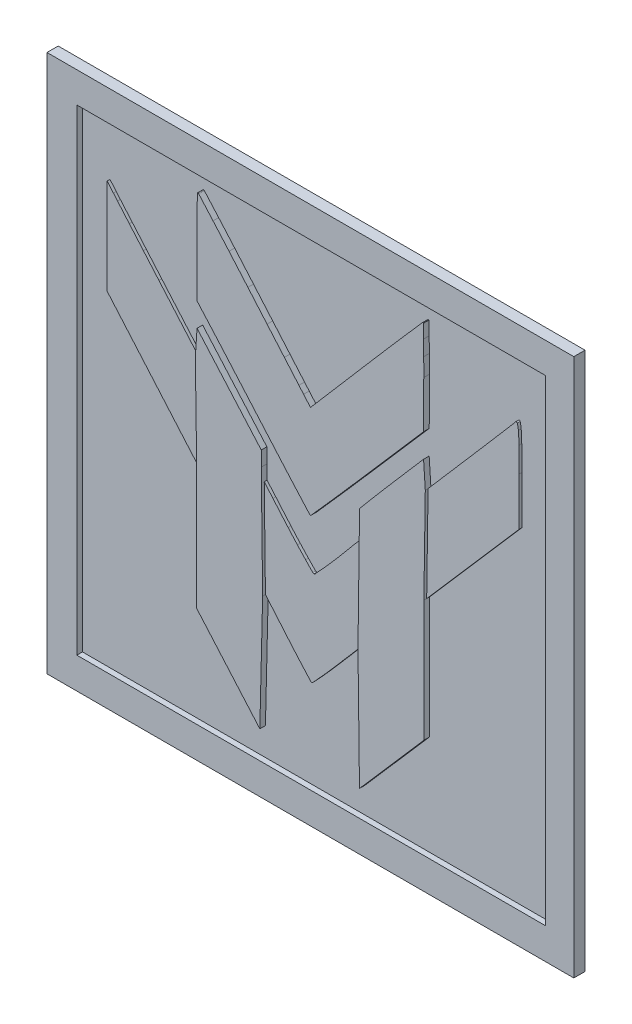
from build123d import *

# Parameters (mm, degrees)
MODEL_W                 = 187.865079392
MODEL_H                 = 191.895039876
MODEL_W_2               = 167.051581688
MODEL_H_2               = 169.92041531
SALIENTE_EXTRUIR1_DEPTH = 4
MODEL_3_W               = 167.051581688
MODEL_3_H               = 169.92041531
SALIENTE_EXTRUIR2_DEPTH = 2
SALIENTE_EXTRUIR3_DEPTH = 4
SALIENTE_EXTRUIR4_DEPTH = 3


with BuildPart() as part:
    # Model → Saliente-Extruir1 (new body)
    with BuildSketch(Plane.XY):
        with Locations((73.531542, 75.5)):
            Rectangle(MODEL_W, MODEL_H)
        with Locations((73.774397, 75.60926)):
            Rectangle(MODEL_W_2, MODEL_H_2, mode=Mode.SUBTRACT)
    extrude(amount=SALIENTE_EXTRUIR1_DEPTH)

    # Model_3 → Saliente-Extruir2 (add)
    with BuildSketch(Plane.XY):
        with Locations((73.774397, 75.60926)):
            Rectangle(MODEL_3_W, MODEL_3_H)
        with BuildLine():
            Line((7.2e-05, 107.5), (0.035999, 124.5))
            Line((0.035999, 124.5), (0.071926, 141.5))
            Line((0.071926, 141.5), (2.285963, 138.871272))
            Line((2.285963, 138.871272), (3.760669, 137.137865))
            Line((3.760669, 137.137865), (7.962127, 132.252038))
            Line((7.962127, 132.252038), (12.976309, 126.430829))
            Line((12.976309, 126.430829), (18.5, 120.029115))
            Line((18.5, 120.029115), (32.5, 103.815685))
            Line((32.5, 103.815685), (32.80535, 108.421532))
            Line((32.80535, 108.421532), (33.110701, 113.027379))
            Line((33.110701, 113.027379), (56.014045, 86.882719623))
            Line((56.014045, 86.882719623), (56.014045, 81.586526))
            Line((56.014045, 81.586526), (56.075171593, 76.607524733))
            Line((56.075171593, 76.607524733), (59.193446, 73.008717))
            ThreePointArc((59.193446, 73.008717), (61.875260227, 69.866972201), (64.585827, 66.75))
            ThreePointArc((64.585827, 66.75), (66.243062882, 64.877065991), (67.915255, 63.017473))
            ThreePointArc((67.915255, 63.017473), (69.362114385, 61.441684708), (70.828956, 59.88448))
            Line((70.828956, 59.88448), (73.38197, 57.22976))
            ThreePointArc((73.38197, 57.22976), (73.583472519, 57.099124116), (73.821783, 57.069508))
            ThreePointArc((73.821783, 57.069508), (74.059199996, 57.138361311), (74.257102, 57.286491))
            Line((74.257102, 57.286491), (76.723497, 59.962242))
            ThreePointArc((76.723497, 59.962242), (78.138911281, 61.525374547), (79.537207, 63.103839))
            ThreePointArc((79.537207, 63.103839), (81.148823539, 64.956113153), (82.747569, 66.819508))
            ThreePointArc((82.747569, 66.819508), (85.322470724, 69.871815466), (87.86746, 72.949108))
            Line((87.86746, 72.949108), (90.938203107, 76.495855987))
            Line((90.938203107, 76.495855987), (91.003279, 81.5))
            Line((91.003279, 81.5), (91.003279, 86.276217564))
            Line((91.003279, 86.276217564), (95.077112, 91.103725))
            ThreePointArc((95.077112, 91.103725), (98.751620148, 95.432315079), (102.451353, 99.739365))
            Line((102.451353, 99.739365), (113.891286, 112.97873))
            Line((113.891286, 112.97873), (114.195643, 108.344383))
            Line((114.195643, 108.344383), (114.5, 103.710036))
            Line((114.5, 103.710036), (129.5, 121.052263))
            Line((129.5, 121.052263), (135.336044, 127.810066))
            Line((135.336044, 127.810066), (140.451595, 133.756333))
            Line((140.451595, 133.756333), (144.806497, 138.835291))
            ThreePointArc((144.806497, 138.835291), (145.268329868, 139.386362598), (145.718197, 139.947245))
            ThreePointArc((145.718197, 139.947245), (146.056902292, 140.073181551), (146.32298, 139.828674))
            ThreePointArc((146.32298, 139.828674), (146.561505098, 138.803778786), (146.697812, 137.760359))
            ThreePointArc((146.697812, 137.760359), (146.839403633, 135.533225879), (146.905079, 133.302563))
            ThreePointArc((146.905079, 133.302563), (146.948292555, 128.879665158), (146.968197, 124.456601))
            Line((146.968197, 124.456601), (147, 107.413202))
            Line((147, 107.413202), (130.500632, 88.456601))
            Line((130.500632, 88.456601), (114.001264, 69.5))
            Line((114.001264, 69.5), (114.000632, 47.875318))
            Line((114.000632, 47.875318), (114, 26.250637))
            Line((114, 26.250637), (102.519669, 13.065559))
            Line((102.519669, 13.065559), (91.039338, -0.119518))
            Line((91.039338, -0.119518), (90.769669, 21.339906))
            Line((90.769669, 21.339906), (90.5, 42.799331))
            Line((90.5, 42.799331), (82, 32.93022))
            ThreePointArc((82, 32.93022), (80.35813032, 31.034967776), (78.70536, 29.149214))
            ThreePointArc((78.70536, 29.149214), (77.285058443, 27.553090209), (75.85, 25.970221))
            Line((75.85, 25.970221), (73.32744, 23.22557))
            ThreePointArc((73.32744, 23.22557), (73.178514606, 23.123260258), (73, 23.095357))
            ThreePointArc((73, 23.095357), (72.8221346, 23.142689469), (72.674888, 23.25312))
            Line((72.674888, 23.25312), (70.296875, 25.89166))
            ThreePointArc((70.296875, 25.89166), (68.943226003, 27.413217252), (67.602841, 28.946472))
            ThreePointArc((67.602841, 28.946472), (66.046502566, 30.752317291), (64.5, 32.566593))
            Line((64.5, 32.566593), (56.5, 42.003581))
            Line((56.5, 42.003581), (56, 21.264818))
            Line((56, 21.264818), (55.5, 0.526056))
            Line((55.5, 0.526056), (44.25, 13.478546))
            Line((44.25, 13.478546), (33, 26.431037))
            Line((33, 26.431037), (33, 47.825406))
            Line((33, 47.825406), (33, 69.219776))
            Line((33, 69.219776), (16.500036, 88.359888))
            Line((16.500036, 88.359888), (7.2e-05, 107.5))
        make_face(mode=Mode.SUBTRACT)
        with BuildLine():
            Line((33.081557, 121.5), (33.040779, 138.25))
            ThreePointArc((33.040779, 138.25), (33.040372412, 141.461401183), (33.054796, 144.67277))
            ThreePointArc((33.054796, 144.67277), (33.083588886, 147.376379875), (33.133193, 150.079688))
            Line((33.133193, 150.079688), (33.244463, 154.835902))
            ThreePointArc((33.244463, 154.835902), (33.295158013, 154.952178847), (33.412646, 155))
            ThreePointArc((33.412646, 155), (33.564379261, 154.967326432), (33.689217, 154.875098))
            Line((33.689217, 154.875098), (38.818235, 149.051562))
            ThreePointArc((38.818235, 149.051562), (41.680167001, 145.787991937), (44.530312, 142.514123))
            Line((44.530312, 142.514123), (51.235194, 134.75))
            Line((51.235194, 134.75), (58.083392, 126.785627))
            Line((58.083392, 126.785627), (64.253973, 119.611402))
            Line((64.253973, 119.611402), (69.439973, 113.58357))
            Line((69.439973, 113.58357), (71.106496, 111.650516))
            Line((71.106496, 111.650516), (73.567895, 108.801033))
            Line((73.567895, 108.801033), (93.436062, 131.900516))
            Line((93.436062, 131.900516), (101.079, 140.757394))
            ThreePointArc((101.079, 140.757394), (104.319587907, 144.490299831), (107.570146, 148.214527))
            Line((107.570146, 148.214527), (113.417907, 154.893792))
            ThreePointArc((113.417907, 154.893792), (113.52353223, 154.97220757), (113.652114, 155))
            ThreePointArc((113.652114, 155), (113.751521904, 154.959401446), (113.794088, 154.86082))
            Line((113.794088, 154.86082), (113.88506, 150.079688))
            ThreePointArc((113.88506, 150.079688), (113.925426412, 147.376336544), (113.948242, 144.67278))
            ThreePointArc((113.948242, 144.67278), (113.958670365, 141.461398132), (113.9566, 138.25))
            Line((113.9566, 138.25), (113.9132, 121.5))
            Line((113.9132, 121.5), (93.902354, 98.5))
            Line((93.902354, 98.5), (86.203861, 89.681292))
            ThreePointArc((86.203861, 89.681292), (82.939012216, 85.964274814), (79.663954, 82.25625))
            Line((79.663954, 82.25625), (73.774397, 75.60926))
            ThreePointArc((73.774397, 75.60926), (73.664692606, 75.528572751), (73.531542, 75.5))
            ThreePointArc((73.531542, 75.5), (73.399066228, 75.528375147), (73.289835, 75.608522))
            Line((73.289835, 75.608522), (68.818749, 80.640625))
            ThreePointArc((68.818749, 80.640625), (66.32370187, 83.460951158), (63.838858, 86.290271))
            Line((63.838858, 86.290271), (57.993476, 93))
            Line((57.993476, 93), (51.825624, 100.103214))
            Line((51.825624, 100.103214), (45.844288, 106.975))
            Line((45.844288, 106.975), (40.726176, 112.840706))
            Line((40.726176, 112.840706), (37.948467, 116))
            Line((37.948467, 116), (33.081557, 121.5))
        make_face(mode=Mode.SUBTRACT)
    extrude(amount=SALIENTE_EXTRUIR2_DEPTH)

    # Model_4 → Saliente-Extruir3 (add)
    with BuildSketch(Plane.XY):
        with BuildLine():
            ThreePointArc((33.054796, 144.67277), (33.040372412, 141.461401183), (33.040779, 138.25))
            Line((33.040779, 138.25), (33.081557, 121.5))
            Line((33.081557, 121.5), (37.948467, 116))
            Line((37.948467, 116), (40.726176, 112.840706))
            Line((40.726176, 112.840706), (45.844288, 106.975))
            Line((45.844288, 106.975), (51.825624, 100.103214))
            Line((51.825624, 100.103214), (57.993476, 93))
            Line((57.993476, 93), (63.838858, 86.290271))
            ThreePointArc((63.838858, 86.290271), (66.32370187, 83.460951158), (68.818749, 80.640625))
            Line((68.818749, 80.640625), (73.289835, 75.608522))
            ThreePointArc((73.289835, 75.608522), (73.399066228, 75.528375147), (73.531542, 75.5))
            ThreePointArc((73.531542, 75.5), (73.664692606, 75.528572751), (73.774397, 75.60926))
            Line((73.774397, 75.60926), (79.663954, 82.25625))
            ThreePointArc((79.663954, 82.25625), (82.939012216, 85.964274814), (86.203861, 89.681292))
            Line((86.203861, 89.681292), (93.902354, 98.5))
            Line((93.902354, 98.5), (113.9132, 121.5))
            Line((113.9132, 121.5), (113.9566, 138.25))
            ThreePointArc((113.9566, 138.25), (113.958670365, 141.461398132), (113.948242, 144.67278))
            ThreePointArc((113.948242, 144.67278), (113.925426412, 147.376336544), (113.88506, 150.079688))
            Line((113.88506, 150.079688), (113.794088, 154.86082))
            ThreePointArc((113.794088, 154.86082), (113.751521904, 154.959401446), (113.652114, 155))
            ThreePointArc((113.652114, 155), (113.52353223, 154.97220757), (113.417907, 154.893792))
            Line((113.417907, 154.893792), (107.570146, 148.214527))
            ThreePointArc((107.570146, 148.214527), (104.319587907, 144.490299831), (101.079, 140.757394))
            Line((101.079, 140.757394), (93.436062, 131.900516))
            Line((93.436062, 131.900516), (73.567895, 108.801033))
            Line((73.567895, 108.801033), (71.106496, 111.650516))
            Line((71.106496, 111.650516), (69.439973, 113.58357))
            Line((69.439973, 113.58357), (64.253973, 119.611402))
            Line((64.253973, 119.611402), (58.083392, 126.785627))
            Line((58.083392, 126.785627), (51.235194, 134.75))
            Line((51.235194, 134.75), (44.530312, 142.514123))
            ThreePointArc((44.530312, 142.514123), (41.680167001, 145.787991937), (38.818235, 149.051562))
            Line((38.818235, 149.051562), (33.689217, 154.875098))
            ThreePointArc((33.689217, 154.875098), (33.564379261, 154.967326432), (33.412646, 155))
            ThreePointArc((33.412646, 155), (33.295158013, 154.952178847), (33.244463, 154.835902))
            Line((33.244463, 154.835902), (33.133193, 150.079688))
            ThreePointArc((33.133193, 150.079688), (33.083588886, 147.376379875), (33.054796, 144.67277))
        make_face()
        Polygon((32.5, 103.815685), (33, 69.219776), (33, 26.431037), (44.25, 13.478546), (55.5, 0.526056), (56, 21.264818), (56.5, 42.003581), (56.014045, 81.586526), (56.014045, 86.882719623), (33.110701, 113.027379), (32.80535, 108.421532), align=None)
        with BuildLine():
            Line((91.003279, 81.5), (90.5, 42.799331))
            Line((90.5, 42.799331), (90.769669, 21.339906))
            Line((90.769669, 21.339906), (91.039338, -0.119518))
            Line((91.039338, -0.119518), (102.519669, 13.065559))
            Line((102.519669, 13.065559), (114, 26.250637))
            Line((114, 26.250637), (114.000632, 47.875318))
            Line((114.000632, 47.875318), (114.001264, 69.5))
            Line((114.001264, 69.5), (114.5, 103.710036))
            Line((114.5, 103.710036), (113.891286, 112.97873))
            Line((113.891286, 112.97873), (102.451353, 99.739365))
            ThreePointArc((102.451353, 99.739365), (98.751620148, 95.432315079), (95.077112, 91.103725))
            Line((95.077112, 91.103725), (91.003279, 86.276217564))
            Line((91.003279, 86.276217564), (91.003279, 81.5))
        make_face()
    extrude(amount=SALIENTE_EXTRUIR3_DEPTH)

    # Model_5 → Saliente-Extruir4 (add)
    with BuildSketch(Plane.XY):
        Polygon((0.071926, 141.5), (7.2e-05, 107.5), (33, 69.219776), (32.5, 103.815685), (18.5, 120.029115), (12.976309, 126.430829), (7.962127, 132.252038), (3.760669, 137.137865), (2.285963, 138.871272), align=None)
        with BuildLine():
            Line((56.075171593, 76.607524733), (56.5, 42.003581))
            Line((56.5, 42.003581), (64.5, 32.566593))
            ThreePointArc((64.5, 32.566593), (66.046502566, 30.752317291), (67.602841, 28.946472))
            ThreePointArc((67.602841, 28.946472), (68.943226003, 27.413217252), (70.296875, 25.89166))
            Line((70.296875, 25.89166), (72.674888, 23.25312))
            ThreePointArc((72.674888, 23.25312), (72.8221346, 23.142689469), (73, 23.095357))
            ThreePointArc((73, 23.095357), (73.178514606, 23.123260258), (73.32744, 23.22557))
            Line((73.32744, 23.22557), (75.85, 25.970221))
            ThreePointArc((75.85, 25.970221), (77.285058443, 27.553090209), (78.70536, 29.149214))
            ThreePointArc((78.70536, 29.149214), (80.35813032, 31.034967776), (82, 32.93022))
            Line((82, 32.93022), (90.5, 42.799331))
            Line((90.5, 42.799331), (90.938203107, 76.495855987))
            Line((90.938203107, 76.495855987), (87.86746, 72.949108))
            ThreePointArc((87.86746, 72.949108), (85.322470724, 69.871815466), (82.747569, 66.819508))
            ThreePointArc((82.747569, 66.819508), (81.148823539, 64.956113153), (79.537207, 63.103839))
            ThreePointArc((79.537207, 63.103839), (78.138911281, 61.525374547), (76.723497, 59.962242))
            Line((76.723497, 59.962242), (74.257102, 57.286491))
            ThreePointArc((74.257102, 57.286491), (74.059199996, 57.138361311), (73.821783, 57.069508))
            ThreePointArc((73.821783, 57.069508), (73.583472519, 57.099124116), (73.38197, 57.22976))
            Line((73.38197, 57.22976), (70.828956, 59.88448))
            ThreePointArc((70.828956, 59.88448), (69.362114385, 61.441684708), (67.915255, 63.017473))
            ThreePointArc((67.915255, 63.017473), (66.243062882, 64.877065991), (64.585827, 66.75))
            ThreePointArc((64.585827, 66.75), (61.875260227, 69.866972201), (59.193446, 73.008717))
            Line((59.193446, 73.008717), (56.075171593, 76.607524733))
        make_face()
        with BuildLine():
            Line((114.5, 103.710036), (114.001264, 69.5))
            Line((114.001264, 69.5), (147, 107.413202))
            Line((147, 107.413202), (146.968197, 124.456601))
            ThreePointArc((146.968197, 124.456601), (146.948292555, 128.879665158), (146.905079, 133.302563))
            ThreePointArc((146.905079, 133.302563), (146.839403633, 135.533225879), (146.697812, 137.760359))
            ThreePointArc((146.697812, 137.760359), (146.561505098, 138.803778786), (146.32298, 139.828674))
            ThreePointArc((146.32298, 139.828674), (146.056902292, 140.073181551), (145.718197, 139.947245))
            ThreePointArc((145.718197, 139.947245), (145.268329868, 139.386362598), (144.806497, 138.835291))
            Line((144.806497, 138.835291), (140.451595, 133.756333))
            Line((140.451595, 133.756333), (135.336044, 127.810066))
            Line((135.336044, 127.810066), (129.5, 121.052263))
            Line((129.5, 121.052263), (114.5, 103.710036))
        make_face()
    extrude(amount=SALIENTE_EXTRUIR4_DEPTH)


solid = part.part
